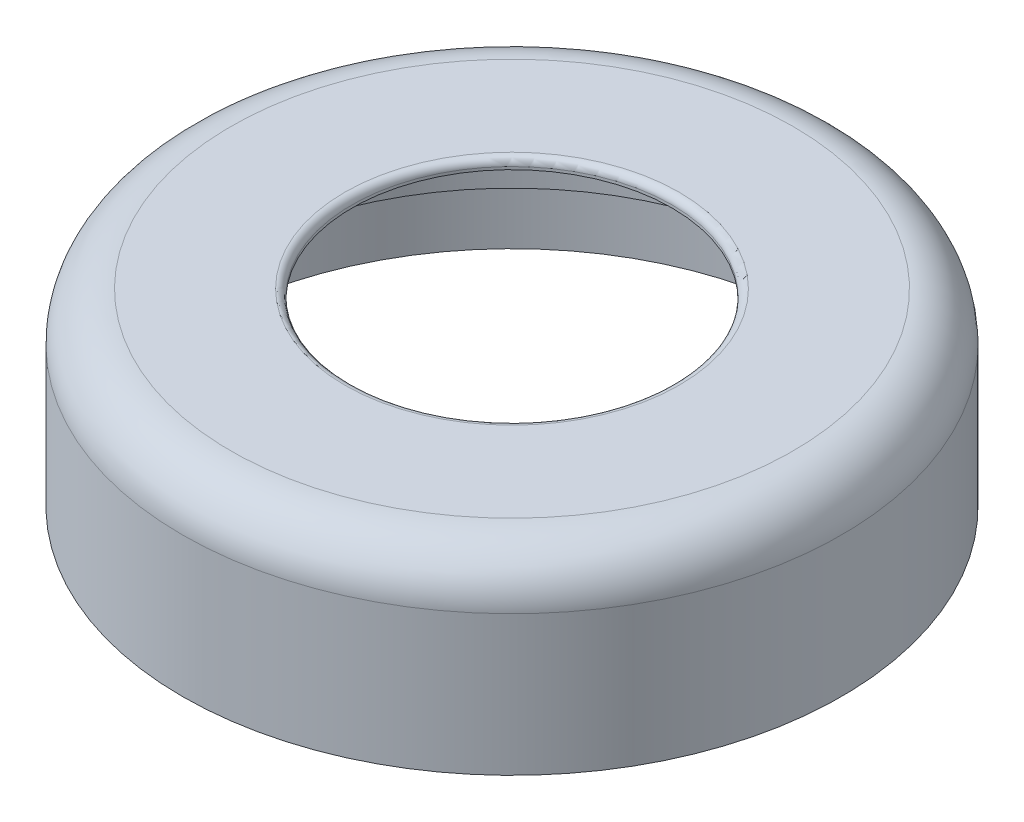
from build123d import *

# Parameters (mm, degrees)
FILLET2_R           = 0.75
BOSS_EXTRUDE4_DEPTH = 7


with BuildPart() as part:
    # Sketch5 → Revolve1 (revolve)
    with BuildSketch(Plane.XY):
        with BuildLine():
            Line((30.3, 7.697016625), (30.3, 16.110174346))
            ThreePointArc((30.3, 16.110174346), (29.421320344, 18.23149469), (27.3, 19.110174346))
            Line((27.3, 19.110174346), (22.498120145, 19.110174346))
            Line((22.498120145, 19.110174346), (16.498120145, 19.110174346))
            Line((16.498120145, 19.110174346), (16.498120145, 20.138377289))
            Line((16.498120145, 20.138377289), (29, 20.138377289))
            ThreePointArc((29, 20.138377289), (32.535533906, 18.673911195), (34, 15.138377289))
            Line((34, 15.138377289), (34, 0.697016625))
            Line((34, 0.697016625), (32.55, 0.697016625))
            Line((32.55, 0.697016625), (32.55, 7.697016625))
            Line((32.55, 7.697016625), (30.3, 7.697016625))
        make_face()
    revolve(axis=Axis((0, 0, 0), (0, 1, 0)))

    # Fillet2
    fillet2_edges = [part.edges().sort_by_distance(p)[0] for p in [
        (-16.498120145, 20.138377289, 0),
    ]]
    fillet(fillet2_edges, radius=FILLET2_R)

    # Sketch8 → Boss-Extrude4 (add)
    with BuildSketch(Plane.XZ.offset(-0.697016625)):
        with BuildLine():
            Line((-5, -30.163682936), (5, -30.163682936))
            Line((5, -30.163682936), (5, -32.163682936))
            ThreePointArc((5, -32.163682936), (0, -32.55), (-5, -32.163682936))
            Line((-5, -32.163682936), (-5, -30.163682936))
        make_face()
        with BuildLine():
            Line((-28.622515694, 10.751714449), (-30.354566502, 11.751714449))
            ThreePointArc((-30.354566502, 11.751714449), (-28.189126893, 16.275), (-25.354566502, 20.411968487))
            Line((-25.354566502, 20.411968487), (-23.622515694, 19.411968487))
            Line((-23.622515694, 19.411968487), (-28.622515694, 10.751714449))
        make_face()
        with BuildLine():
            Line((23.622515694, 19.411968487), (25.354566502, 20.411968487))
            ThreePointArc((25.354566502, 20.411968487), (28.189126893, 16.275), (30.354566502, 11.751714449))
            Line((30.354566502, 11.751714449), (28.622515694, 10.751714449))
            Line((28.622515694, 10.751714449), (23.622515694, 19.411968487))
        make_face()
    extrude(amount=-BOSS_EXTRUDE4_DEPTH)


solid = part.part
